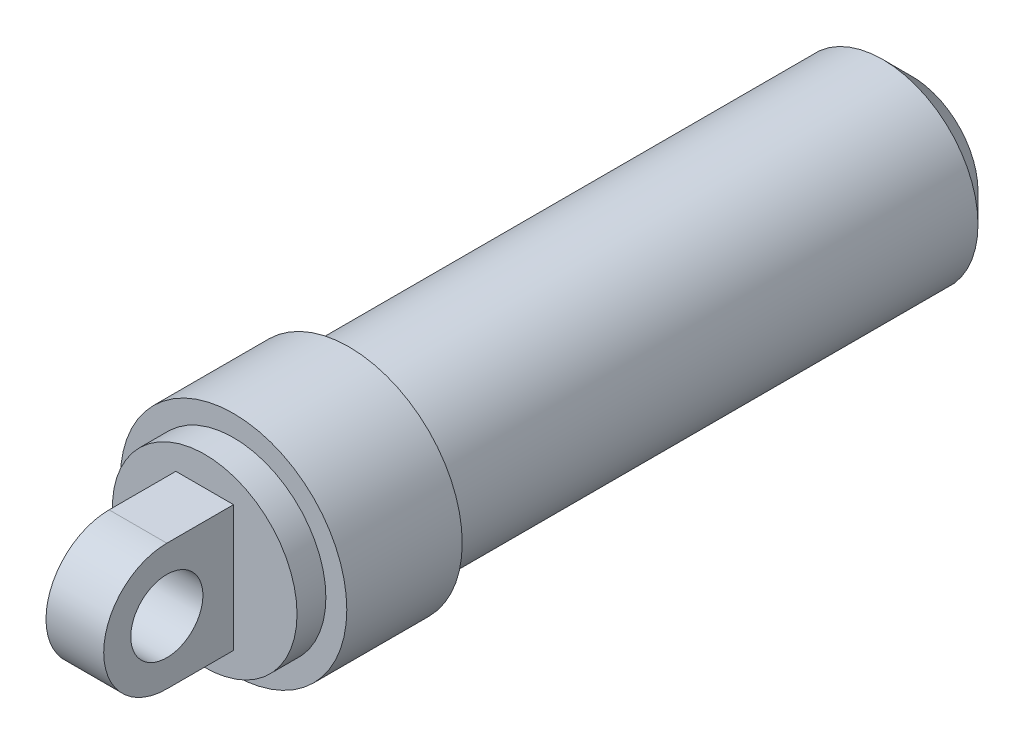
from build123d import *

# Parameters (mm, degrees)
SKETCH2_R            = 6.6
EXTERNAL_SHOCK_DEPTH = 39
SHOCK_CHAMFER_SIZE   = 2
SKETCH3_R            = 7.85
CYLINDER_A_DEPTH     = 8
SKETCH4_R            = 6.4
CYLINDER_B_DEPTH     = 2
MOUNTING_BOSS_DEPTH  = 2
SKETCH6_R            = 2.5
MOUNTING_HOLE_DEPTH  = 4
SKETCH7_R            = 1.5
INNER_HOLE_DEPTH     = 35


with BuildPart() as part:
    # Sketch2 → External Shock (new body)
    with BuildSketch(Plane.XY):
        Circle(SKETCH2_R)
    extrude(amount=EXTERNAL_SHOCK_DEPTH)

    # Shock Chamfer
    shock_chamfer_edges = [part.edges().sort_by_distance(p)[0] for p in [
        (-6.6, 0, 0),
    ]]
    chamfer(shock_chamfer_edges, length=SHOCK_CHAMFER_SIZE)

    # Sketch3 → Cylinder A (add)
    with BuildSketch(Plane.XY.offset(39)):
        Circle(SKETCH3_R)
    extrude(amount=CYLINDER_A_DEPTH)

    # Sketch4 → Cylinder B (add)
    with BuildSketch(Plane.XY.offset(47)):
        Circle(SKETCH4_R)
    extrude(amount=CYLINDER_B_DEPTH)

    # Sketch5 → Mounting Boss (add, symmetric)
    with BuildSketch(Plane(origin=(0, 0, 0), x_dir=(0, 0, -1), z_dir=(1, 0, 0))):
        with BuildLine():
            Line((-53.625, -4.375), (-49, -4.375))
            Line((-49, -4.375), (-49, 4.375))
            Line((-49, 4.375), (-53.625, 4.375))
            ThreePointArc((-53.625, 4.375), (-58, 0), (-53.625, -4.375))
        make_face()
    extrude(amount=MOUNTING_BOSS_DEPTH, both=True)

    # Sketch6 → Mounting Hole (cut)
    with BuildSketch(Plane.ZY.offset(2)):
        with Locations((53.625, 0)):
            Circle(SKETCH6_R)
    extrude(amount=-MOUNTING_HOLE_DEPTH, mode=Mode.SUBTRACT)

    # Sketch7 → Inner Hole (cut)
    with BuildSketch(Plane(origin=(0, 0, 0), x_dir=(-1, 0, 0), z_dir=(0, 0, -1))):
        Circle(SKETCH7_R)
    extrude(amount=-INNER_HOLE_DEPTH, mode=Mode.SUBTRACT)


solid = part.part
